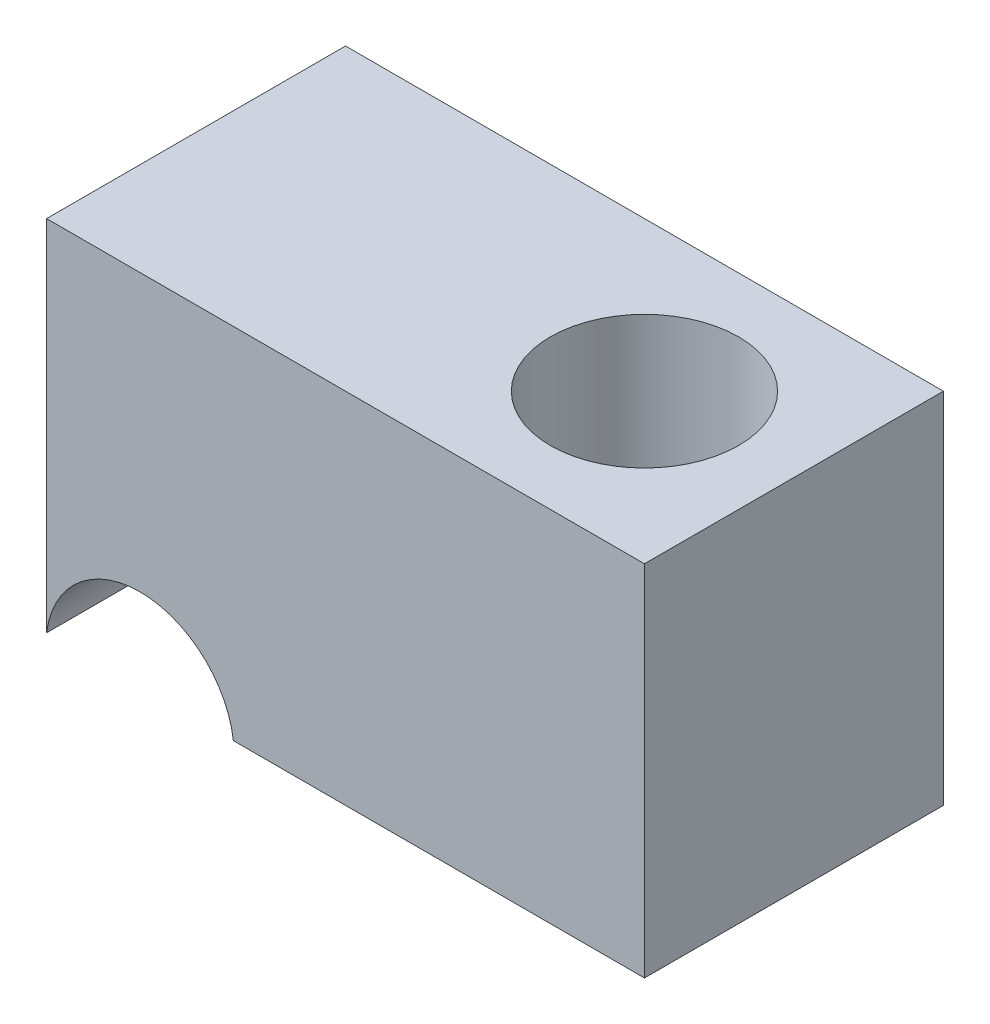
from build123d import *

# Parameters (mm, degrees)
BOSS_EXTRUDE1_DEPTH             = 6.35
F_4_0MM_DOWEL_HOLE1_D           = 4
F_4_0MM_DOWEL_HOLE1_CSINK_D     = 4.05
F_4_0MM_DOWEL_HOLE1_CSINK_ANGLE = 90


with BuildPart() as part:
    # Sketch1 → Boss-Extrude1 (new body)
    with BuildSketch(Plane.XY):
        with BuildLine():
            Line((0, 0), (-8.732389132, 0))
            ThreePointArc((-8.732389132, 0), (-10.716194566, 1.746), (-12.7, 0))
            Line((-12.7, 0), (-12.7, 7.62))
            Line((-12.7, 7.62), (0, 7.62))
            Line((0, 7.62), (0, 0))
        make_face()
    extrude(amount=BOSS_EXTRUDE1_DEPTH)

    # Ø4.0mm Dowel Hole1 (through all)
    with Locations(Plane(origin=(0, 0, 0), x_dir=(-1, 0, 0), z_dir=(0, -1, 0))):
        with Locations((3.175, -3.175)):
            CounterSinkHole(F_4_0MM_DOWEL_HOLE1_D / 2, F_4_0MM_DOWEL_HOLE1_CSINK_D / 2, counter_sink_angle=F_4_0MM_DOWEL_HOLE1_CSINK_ANGLE)


solid = part.part
